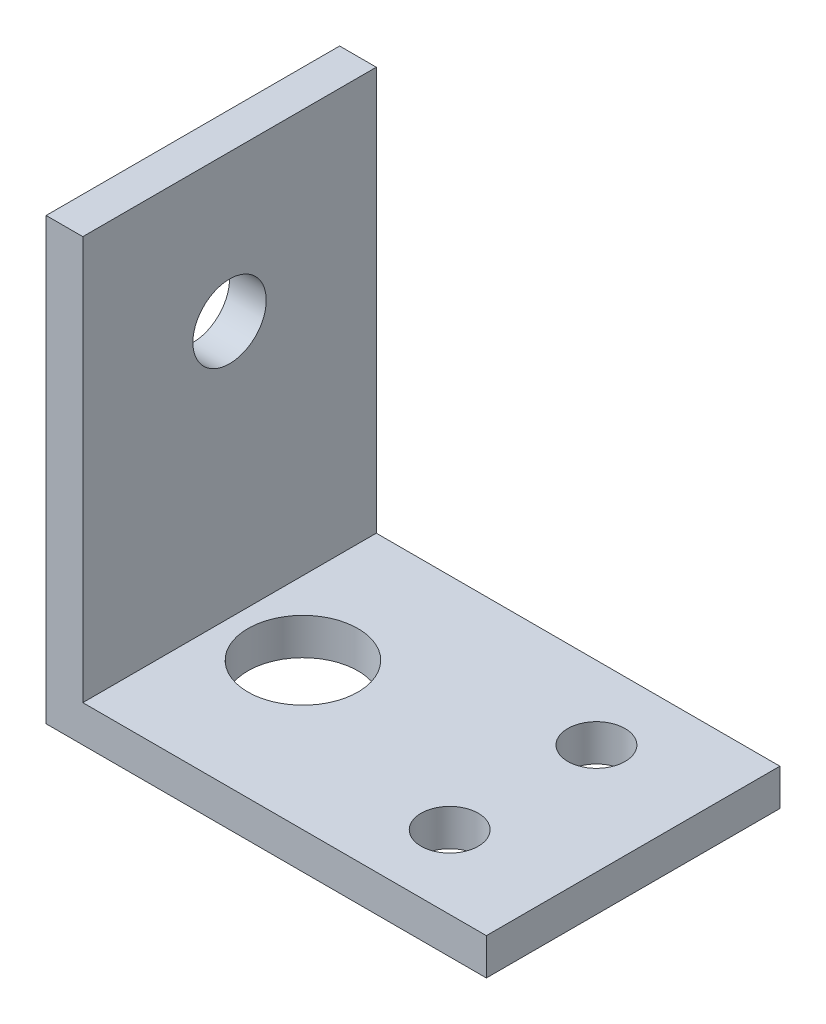
from build123d import *

# Parameters (mm, degrees)
EXTRUDE_THIN1_DEPTH = 25.4
SKETCH2_R           = 4.7625
CUT_EXTRUDE1_DEPTH  = 4.175
SKETCH3_R           = 2.4765
CUT_EXTRUDE2_DEPTH  = 39.1
SKETCH4_R           = 3.175
CUT_EXTRUDE3_DEPTH  = 39.1


with BuildPart() as part:
    # Sketch1 → Extrude-Thin1 (new body)
    with BuildSketch(Plane.XY):
        Polygon((0, 38.1), (0, 0), (38.1, 0), (38.1, 3.175), (3.175, 3.175), (3.175, 38.1), align=None)
    extrude(amount=EXTRUDE_THIN1_DEPTH)

    # Sketch2 → Cut-Extrude1 (cut, through all)
    with BuildSketch(Plane(origin=(0, 3.175, 0), x_dir=(1, 0, 0), z_dir=(0, 1, 0))):
        with Locations((9.525, -12.7)):
            Circle(SKETCH2_R)
    extrude(amount=-CUT_EXTRUDE1_DEPTH, mode=Mode.SUBTRACT)

    # Sketch3 → Cut-Extrude2 (cut, through all)
    with BuildSketch(Plane.XZ):
        with Locations((28.575, 19.05)):
            Circle(SKETCH3_R)
        with Locations((28.575, 6.35)):
            Circle(SKETCH3_R)
    extrude(amount=-CUT_EXTRUDE2_DEPTH, mode=Mode.SUBTRACT)

    # Sketch4 → Cut-Extrude3 (cut, through all)
    with BuildSketch(Plane.ZY):
        with Locations((12.7, 25.4)):
            Circle(SKETCH4_R)
    extrude(amount=-CUT_EXTRUDE3_DEPTH, mode=Mode.SUBTRACT)


solid = part.part
